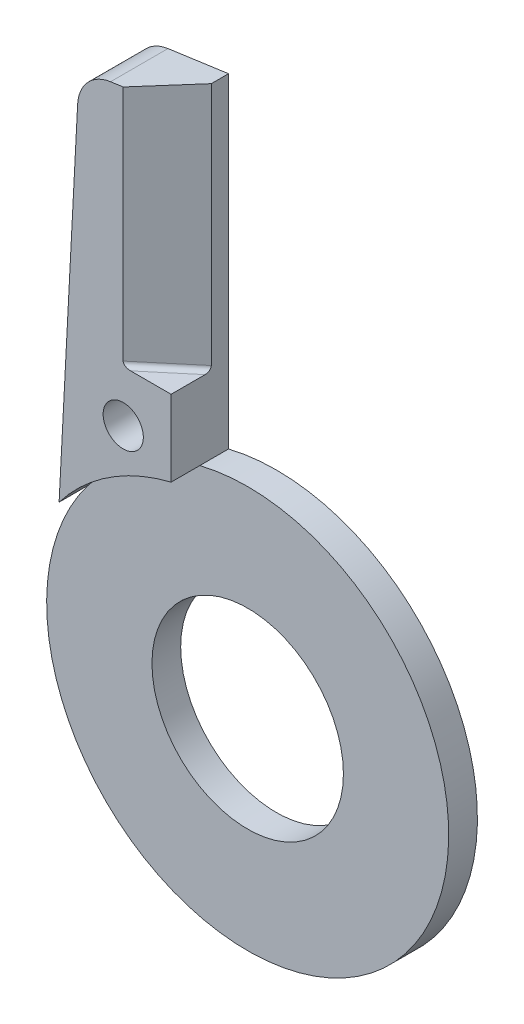
from build123d import *

# Parameters (mm, degrees)
CROQUIS1_R                = 10
SALIENTE_EXTRUIR1_DEPTH   = 6
CROQUIS2_R                = 21
CROQUIS2_R_2              = 10
CORTAR_EXTRUIR1_DEPTH     = 3
CORTAR_EXTRUIR2_DEPTH     = 26
REDONDEO1_R               = 0.5
TALADRO_ROSCADO_M51_D     = 4.2
TALADRO_ROSCADO_M51_DEPTH = 14
TALADRO_ROSCADO_M51_TIP   = 1.2618073


with BuildPart() as part:
    # Croquis1 → Saliente-Extruir1 (new body)
    with BuildSketch(Plane.XY):
        with BuildLine():
            Line((-16.7, 12.732242536), (-14.762225987, 49.707173354))
            ThreePointArc((-14.762225987, 49.707173354), (-13.716817195, 52.20019036), (-11.324400252, 53.458901804))
            Line((-11.324400252, 53.458901804), (-5, 54.347738295))
            Line((-5, 54.347738295), (-5, 20.396078054))
            ThreePointArc((-5, 20.396078054), (11.506784682, -17.566841102), (-16.7, 12.732242536))
        make_face()
        Circle(CROQUIS1_R, mode=Mode.SUBTRACT)
    extrude(amount=SALIENTE_EXTRUIR1_DEPTH)

    # Croquis2 → Cortar-Extruir1 (cut)
    with BuildSketch(Plane.XY.offset(6)):
        Circle(CROQUIS2_R)
        Circle(CROQUIS2_R_2, mode=Mode.SUBTRACT)
    extrude(amount=-CORTAR_EXTRUIR1_DEPTH, mode=Mode.SUBTRACT)

    # Croquis3 → Cortar-Extruir2 (cut)
    with BuildSketch(Plane(origin=(0, 54.347738295, 0), x_dir=(-1, 0, 0), z_dir=(0, 1, 0))):
        Polygon((10.005365089, 6), (5, 1.8), (5, 6), align=None)
    extrude(amount=-CORTAR_EXTRUIR2_DEPTH, mode=Mode.SUBTRACT)

    # Redondeo1
    redondeo1_edges = [part.edges().sort_by_distance(p)[0] for p in [
        (-7.502682544, 28.347738295, 3.9),
    ]]
    fillet(redondeo1_edges, radius=REDONDEO1_R)

    # Taladro roscado M51
    with Locations(Plane.XY.offset(6)):
        with Locations((-10, 23)):
            Hole(TALADRO_ROSCADO_M51_D / 2, depth=TALADRO_ROSCADO_M51_DEPTH)
            with Locations((0, 0, -(TALADRO_ROSCADO_M51_DEPTH + TALADRO_ROSCADO_M51_TIP / 2))):  # 118° drill point
                Cone(0, TALADRO_ROSCADO_M51_D / 2, TALADRO_ROSCADO_M51_TIP, mode=Mode.SUBTRACT)


solid = part.part
